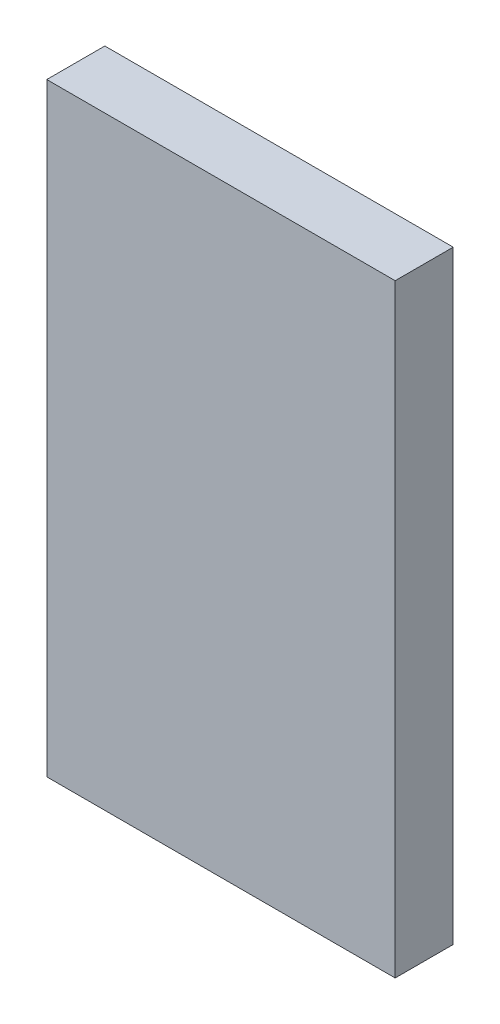
from build123d import *

# Parameters (mm, degrees)
SKETCH1_W           = 26
SKETCH1_H           = 15
BOSS_EXTRUDE1_DEPTH = 2.5


with BuildPart() as part:
    # Sketch1 → Boss-Extrude1 (new body)
    with BuildSketch(Plane(origin=(0, 0, 0), x_dir=(0, 1, 0), z_dir=(0, 0, 1))):
        with Locations((13, 7.5)):
            Rectangle(SKETCH1_W, SKETCH1_H)
    extrude(amount=BOSS_EXTRUDE1_DEPTH)


solid = part.part
